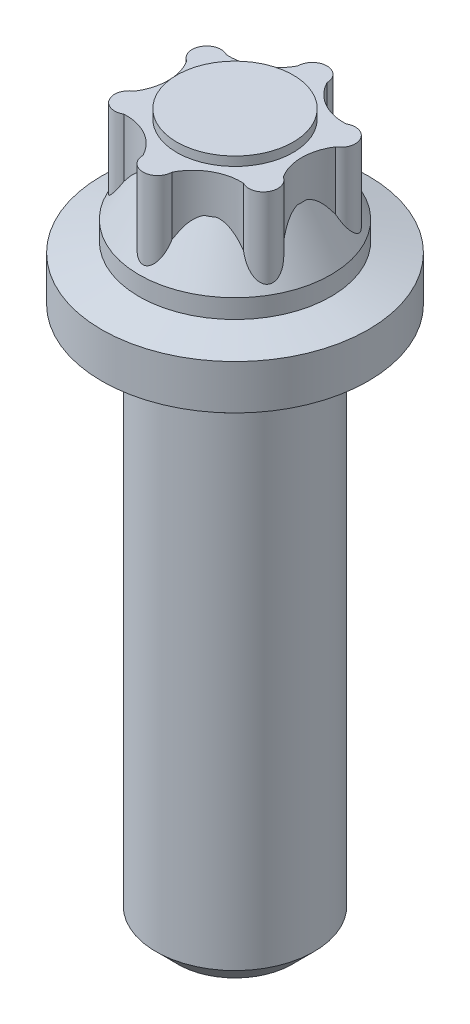
from build123d import *

# Parameters (mm, degrees)
SKIZZE1_R                       = 9.165
AUFSATZ_LINEAR_AUSTRAGEN1_DEPTH = 3.063
SKIZZE20_R                      = 6.6
AUFSATZ_LINEAR_AUSTRAGEN4_DEPTH = 0.69
SKIZZE21_R                      = 6.6
AUFSATZ_LINEAR_AUSTRAGEN5_DEPTH = 1.3
SKIZZE22_R                      = 4
AUFSATZ_LINEAR_AUSTRAGEN6_DEPTH = 6.6
SKIZZE22_3_R                    = 4
AUFSATZ_LINEAR_AUSTRAGEN7_DEPTH = 5.98
SKIZZE28_R                      = 8.315
AUFSATZ_LINEAR_AUSTRAGEN8_DEPTH = 0.6
SKIZZE29_R                      = 5.435
AUFSATZ_LINEAR_AUSTRAGEN9_DEPTH = 36.75
VERRUNDUNG1_R                   = 0.6
FASE1_SIZE                      = 1.5


with BuildPart() as part:
    # Skizze1 → Aufsatz-Linear austragen1 (new body)
    with BuildSketch(Plane(origin=(0, 0, 0), x_dir=(1, 0, 0), z_dir=(0, 1, 0))):
        with Locations(Location((0, 0, 0), (0, 0, 270))):  # turned: the seam where the file's is
            Circle(SKIZZE1_R)
    extrude(amount=AUFSATZ_LINEAR_AUSTRAGEN1_DEPTH)

    # Skizze19 → Rotation1 (revolve)
    with BuildSketch(Plane.XY, mode=Mode.PRIVATE) as rotation1_sk:
        Polygon((6.6, 3.063), (6.6, 3.753), (9.165, 3.063), align=None)
    revolve(rotation1_sk.sketch.rotate(Axis((0, 0, 0), (0, 1, 0)), 90), axis=Axis((0, 0, 0), (0, 1, 0)))  # turned: the seam where the file's is

    # Skizze20 → Aufsatz-Linear austragen4 (add)
    with BuildSketch(Plane(origin=(0, 3.063, 0), x_dir=(1, 0, 0), z_dir=(0, 1, 0))):
        Circle(SKIZZE20_R)
    extrude(amount=AUFSATZ_LINEAR_AUSTRAGEN4_DEPTH)

    # Skizze21 → Aufsatz-Linear austragen5 (add)
    with BuildSketch(Plane(origin=(0, 3.753, 0), x_dir=(1, 0, 0), z_dir=(0, 1, 0))):
        with Locations(Location((0, 0, 0), (0, 0, 270))):  # turned: the seam where the file's is
            Circle(SKIZZE21_R)
    extrude(amount=AUFSATZ_LINEAR_AUSTRAGEN5_DEPTH)

    # Skizze22 → Aufsatz-Linear austragen6 (add)
    with BuildSketch(Plane(origin=(0, 5.053, 0), x_dir=(1, 0, 0), z_dir=(0, 1, 0))):
        with Locations(Location((0, 0, 0), (0, 0, 270))):  # turned: the seam where the file's is
            Circle(SKIZZE22_R)
    extrude(amount=AUFSATZ_LINEAR_AUSTRAGEN6_DEPTH)

    # Skizze22_3 → Aufsatz-Linear austragen7 (add)
    with BuildSketch(Plane(origin=(0, 5.053, 0), x_dir=(1, 0, 0), z_dir=(0, 1, 0))):
        with BuildLine():
            ThreePointArc((1, 5.325), (0, 6.325), (-1, 5.325))
            ThreePointArc((-1, 5.325), (-2.295031806, 3.971342442), (-4.115915402, 3.531025404))
            ThreePointArc((-4.115915402, 3.531025404), (-4.821728224, 3.643591377), (-5.42240304, 3.256250954))
            ThreePointArc((-5.42240304, 3.256250954), (-5.477610679, 3.1625), (-5.531197567, 3.067813305))
            ThreePointArc((-5.531197567, 3.067813305), (-5.566306805, 2.353943444), (-5.115915402, 1.798974596))
            ThreePointArc((-5.115915402, 1.798974596), (-4.588162786, 0), (-5.115915402, -1.798974596))
            ThreePointArc((-5.115915402, -1.798974596), (-5.566306805, -2.353943444), (-5.531197567, -3.067813305))
            ThreePointArc((-5.531197567, -3.067813305), (-5.477610679, -3.1625), (-5.42240304, -3.256250954))
            ThreePointArc((-5.42240304, -3.256250954), (-4.821728224, -3.643591377), (-4.115915402, -3.531025404))
            ThreePointArc((-4.115915402, -3.531025404), (-2.295031806, -3.971342442), (-1, -5.325))
            ThreePointArc((-1, -5.325), (0, -6.325), (1, -5.325))
            ThreePointArc((1, -5.325), (2.295031806, -3.971342442), (4.115915402, -3.531025404))
            ThreePointArc((4.115915402, -3.531025404), (5.477610679, -3.1625), (5.115915402, -1.798974596))
            ThreePointArc((5.115915402, -1.798974596), (4.586799345, -0.001884626), (5.111585275, 1.796474596))
            ThreePointArc((5.111585275, 1.796474596), (5.477610679, 3.1625), (4.111585275, 3.528525404))
            ThreePointArc((4.111585275, 3.528525404), (2.29239063, 3.970537041), (1, 5.325))
        make_face()
        with Locations(Location((0, 0, 0), (0, 0, 270))):  # turned: the seam where the file's is
            Circle(SKIZZE22_3_R, mode=Mode.SUBTRACT)
    extrude(amount=AUFSATZ_LINEAR_AUSTRAGEN7_DEPTH)

    # Skizze28 → Aufsatz-Linear austragen8 (add)
    with BuildSketch(Plane.XZ):
        with Locations(Location((0, 0, 0), (0, 0, 90))):  # turned: the seam where the file's is
            Circle(SKIZZE28_R)
    extrude(amount=AUFSATZ_LINEAR_AUSTRAGEN8_DEPTH)

    # Skizze29 → Aufsatz-Linear austragen9 (add)
    with BuildSketch(Plane.XZ.offset(0.6)):
        with Locations(Location((0, 0, 0), (0, 0, 270))):  # turned: the seam where the file's is
            Circle(SKIZZE29_R)
    extrude(amount=AUFSATZ_LINEAR_AUSTRAGEN9_DEPTH)

    # Verrundung1
    verrundung1_edges = [part.edges().sort_by_distance(p)[0] for p in [
        (0, -0.6, 5.435),
    ]]
    fillet(verrundung1_edges, radius=VERRUNDUNG1_R)

    # Skizze32 → Rotation3 (revolve)
    with BuildSketch(Plane.XY, mode=Mode.PRIVATE) as rotation3_sk:
        Polygon((4.611951316, 5.053), (4.611951316, 8.373), (6.6, 5.053), align=None)
    revolve(rotation3_sk.sketch.rotate(Axis((0, 0, 0), (0, 1, 0)), 270), axis=Axis((0, 0, 0), (0, 1, 0)))  # turned: the seam where the file's is

    # Fase1
    fase1_edges = [part.edges().sort_by_distance(p)[0] for p in [
        (0, -37.35, 5.435),
    ]]
    chamfer(fase1_edges, length=FASE1_SIZE)


solid = part.part
